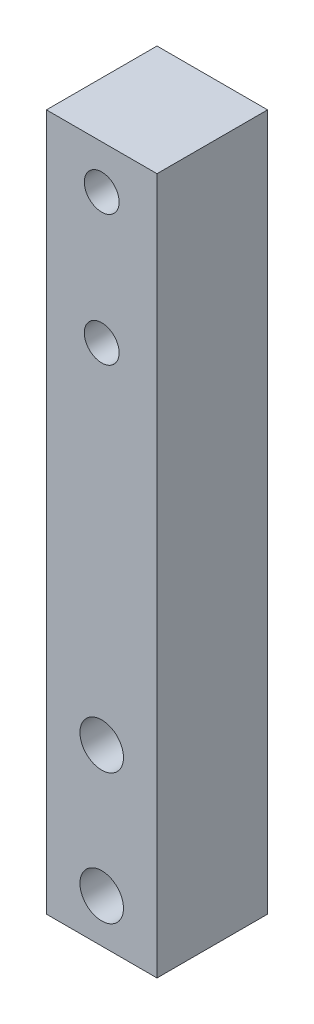
from build123d import *

# Parameters (mm, degrees)
SKETCH1_W           = 12.7
SKETCH1_H           = 80
BOSS_EXTRUDE1_DEPTH = 12.7
SKETCH2_R           = 2.5
SKETCH2_R_2         = 2
CUT_EXTRUDE1_DEPTH  = 13.7


with BuildPart() as part:
    # Sketch1 → Boss-Extrude1 (new body)
    with BuildSketch(Plane.XY):
        with Locations((6.35, 40)):
            Rectangle(SKETCH1_W, SKETCH1_H)
    extrude(amount=BOSS_EXTRUDE1_DEPTH)

    # Sketch2 → Cut-Extrude1 (cut, through all)
    with BuildSketch(Plane.XY):
        with Locations((6.35, 5)):
            Circle(SKETCH2_R)
        with Locations((6.35, 20)):
            Circle(SKETCH2_R)
        with Locations((6.35, 60)):
            Circle(SKETCH2_R_2)
        with Locations((6.35, 75)):
            Circle(SKETCH2_R_2)
    extrude(amount=CUT_EXTRUDE1_DEPTH, mode=Mode.SUBTRACT)


solid = part.part
